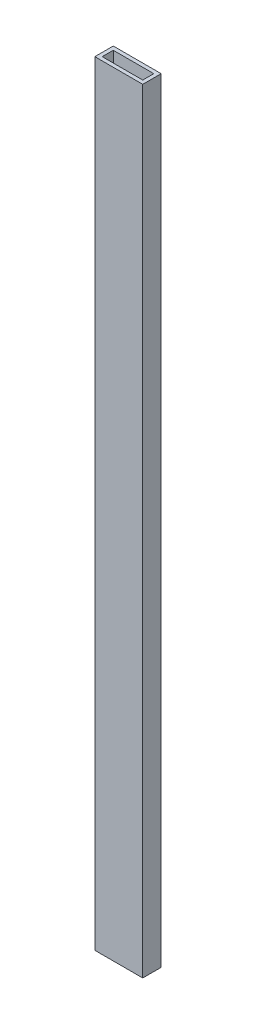
from build123d import *

# Parameters (mm, degrees)
SKETCH1_W           = 41.275
SKETCH1_H           = 15.875
SKETCH1_W_2         = 34.925
SKETCH1_H_2         = 9.525
BOSS_EXTRUDE1_DEPTH = 666.75


with BuildPart() as part:
    # Sketch1 → Boss-Extrude1 (new body)
    with BuildSketch(Plane(origin=(0, 0, 0), x_dir=(1, 0, 0), z_dir=(0, 1, 0))):
        Rectangle(SKETCH1_W, SKETCH1_H)
        Rectangle(SKETCH1_W_2, SKETCH1_H_2, mode=Mode.SUBTRACT)
    extrude(amount=BOSS_EXTRUDE1_DEPTH)


solid = part.part
